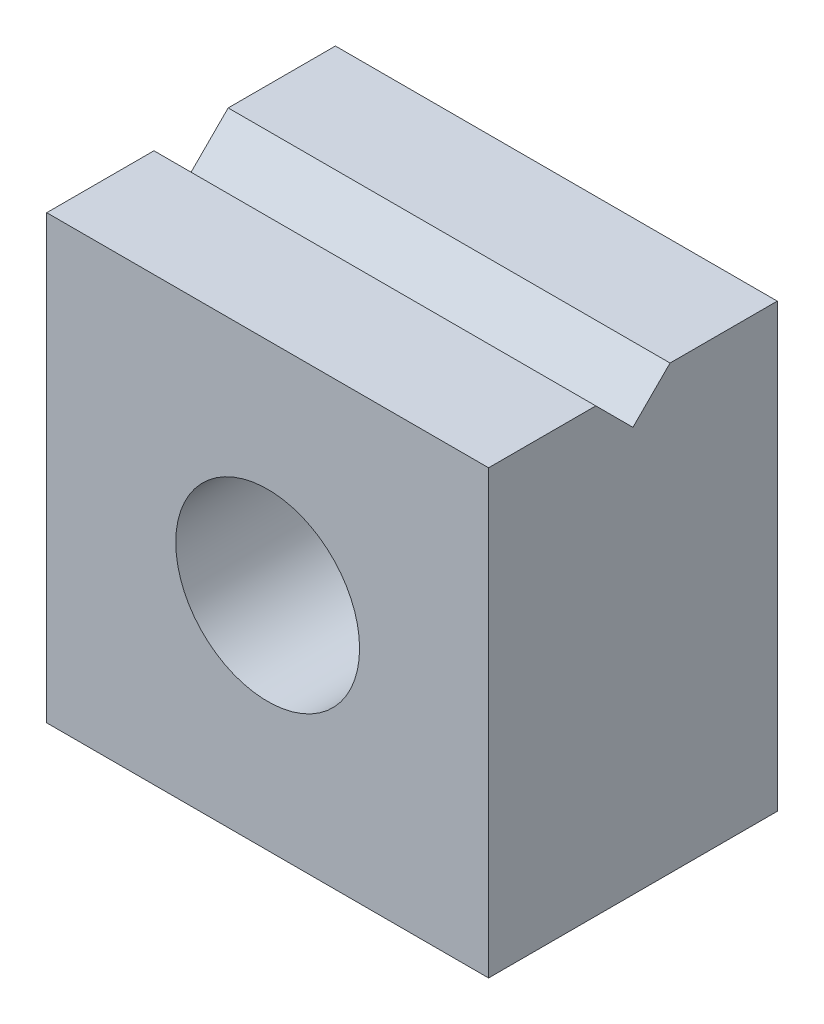
from build123d import *

# Parameters (mm, degrees)
SKETCH1_W               = 7.5
SKETCH1_H               = 7.5
SKETCH1_R               = 1.56
BOSS_EXTRUDE1_DEPTH     = 4.9
CUT_EXTRUDE1_DEPTH      = 4.75
CUT_EXTRUDE1_DEPTH_BACK = 4.75


with BuildPart() as part:
    # Sketch1 → Boss-Extrude1 (new body)
    with BuildSketch(Plane.XY):
        Rectangle(SKETCH1_W, SKETCH1_H)
        Circle(SKETCH1_R, mode=Mode.SUBTRACT)
    extrude(amount=BOSS_EXTRUDE1_DEPTH)

    # Sketch5 → Cut-Extrude1 (cut, two sides)
    with BuildSketch(Plane(origin=(0, 0, 0), x_dir=(0, 0, -1), z_dir=(1, 0, 0))) as cut_extrude1_sk:
        Polygon((-2.45, 3.12), (-3.08, 3.75), (-1.82, 3.75), align=None)
    extrude(amount=CUT_EXTRUDE1_DEPTH, mode=Mode.SUBTRACT)
    extrude(cut_extrude1_sk.sketch, amount=-CUT_EXTRUDE1_DEPTH_BACK, mode=Mode.SUBTRACT)


solid = part.part
